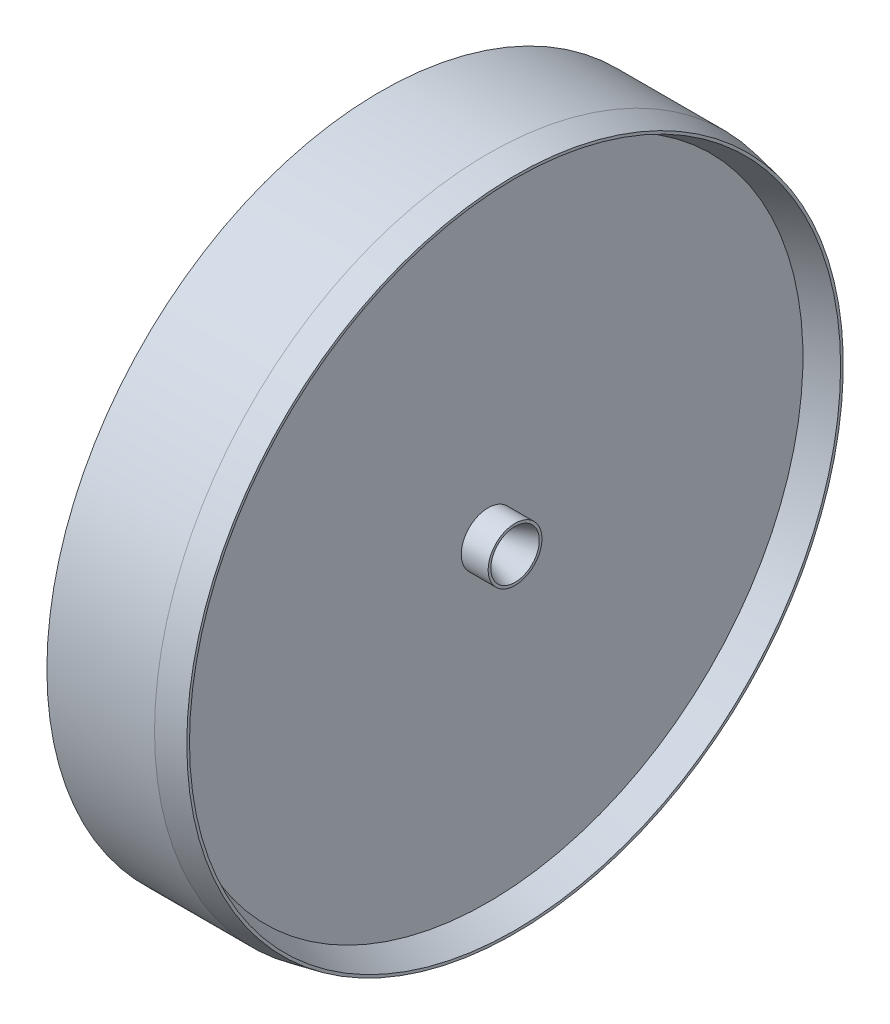
from build123d import *


with BuildPart() as part:
    # Szkic1 → Obrót1 (revolve)
    with BuildSketch(Plane.XY):
        Polygon((0, 12.4), (0, 0), (4, 0), (4, 0.5), (5, 0.9), (5, 1), (4, 1), (4, 11.7), (5, 12.1), (5, 12.2), (4, 12.4), align=None)
    revolve(axis=Axis((0, 0, 0), (1, 0, 0)))


solid = part.part
